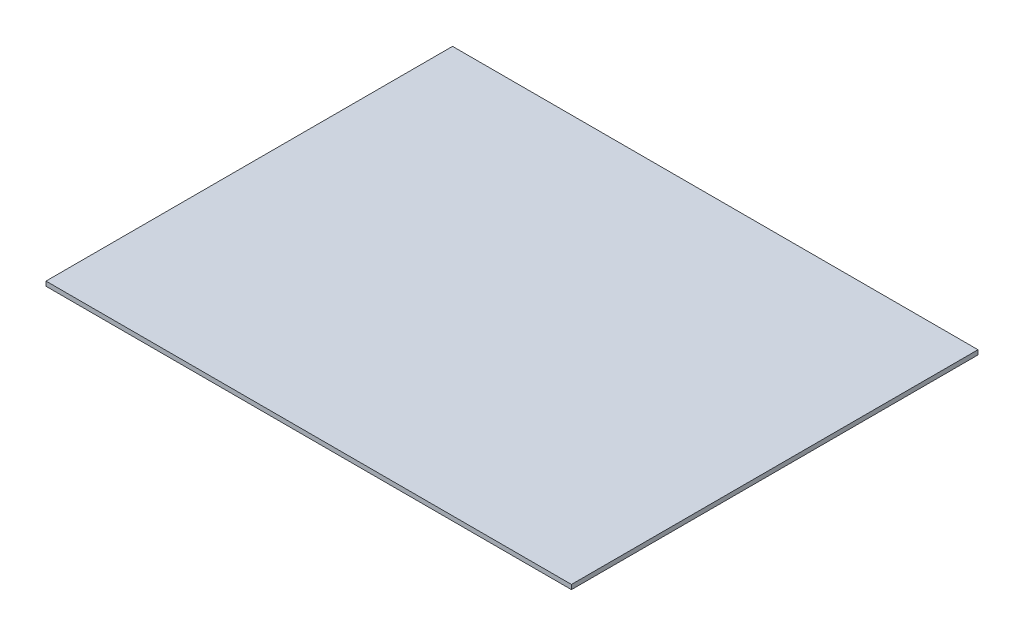
from build123d import *

# Parameters (mm, degrees)
SKETCH_1_W      = 464
SKETCH_1_H      = 359
EXTRUDE_1_DEPTH = 4


with BuildPart() as part:
    # Эскиз1 → Бобышка-Вытянуть1 (new body)
    with BuildSketch(Plane(origin=(0, 0, 0), x_dir=(1, 0, 0), z_dir=(0, 1, 0))):
        Rectangle(SKETCH_1_W, SKETCH_1_H)
    extrude(amount=EXTRUDE_1_DEPTH)


solid = part.part
